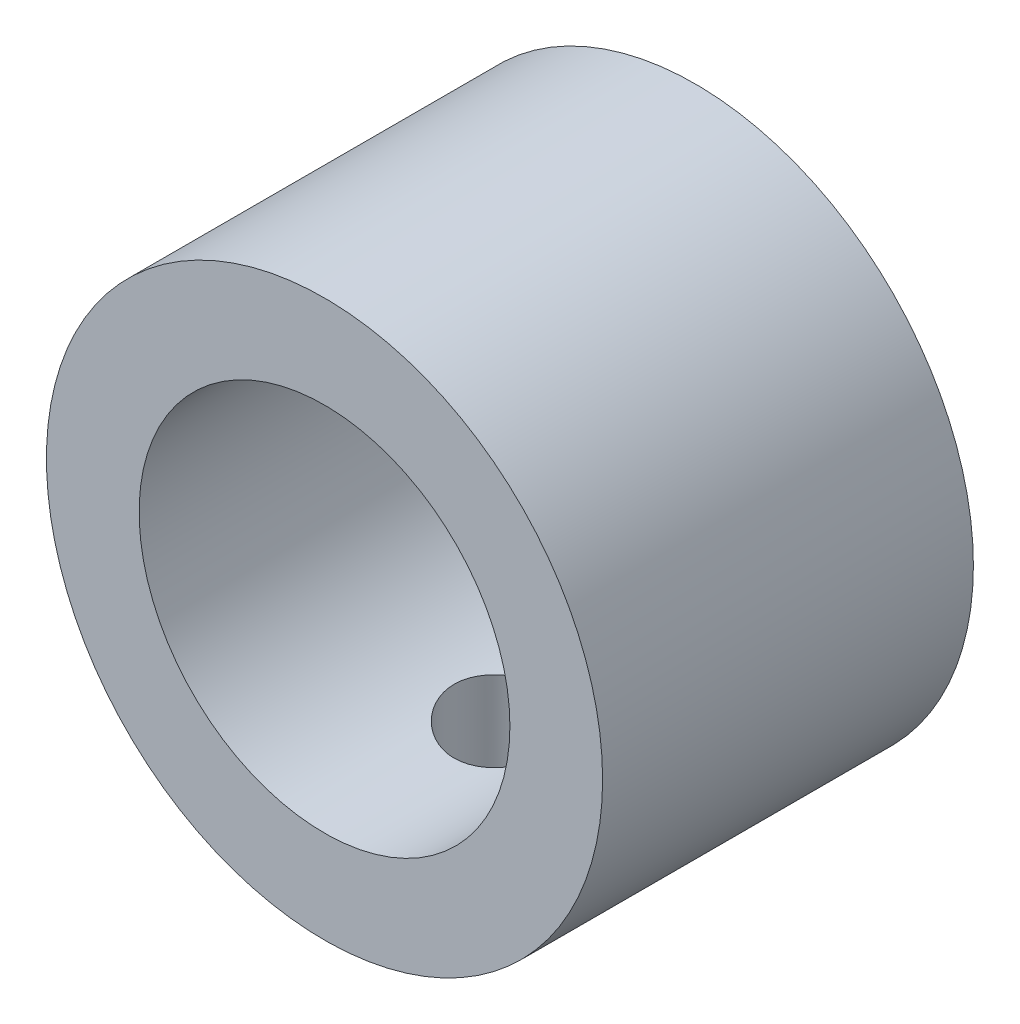
from build123d import *

# Parameters (mm, degrees)
SKETCH1_R           = 7.5
SKETCH1_R_2         = 5
BOSS_EXTRUDE1_DEPTH = 5
CUT_EXTRUDE1_REACH  = 9.5
SKETCH2_R           = 1.5


with BuildPart() as part:
    # Sketch1 → Boss-Extrude1 (new body, symmetric)
    with BuildSketch(Plane.XY):
        Circle(SKETCH1_R)
        Circle(SKETCH1_R_2, mode=Mode.SUBTRACT)
    extrude(amount=BOSS_EXTRUDE1_DEPTH, both=True)

    # Sketch2 → Cut-Extrude1 (cut, up to next)
    with BuildSketch(Plane(origin=(0, 0, 0), x_dir=(1, 0, 0), z_dir=(0, 1, 0)), mode=Mode.PRIVATE) as cut_extrude1_sk1:
        Circle(SKETCH2_R)
    cut_extrude1_tool1 = extrude(cut_extrude1_sk1.sketch, amount=-CUT_EXTRUDE1_REACH, mode=Mode.PRIVATE) & part.part
    add(cut_extrude1_tool1.solids().sort_by_distance((0, 0, 0))[0], mode=Mode.SUBTRACT)


solid = part.part
